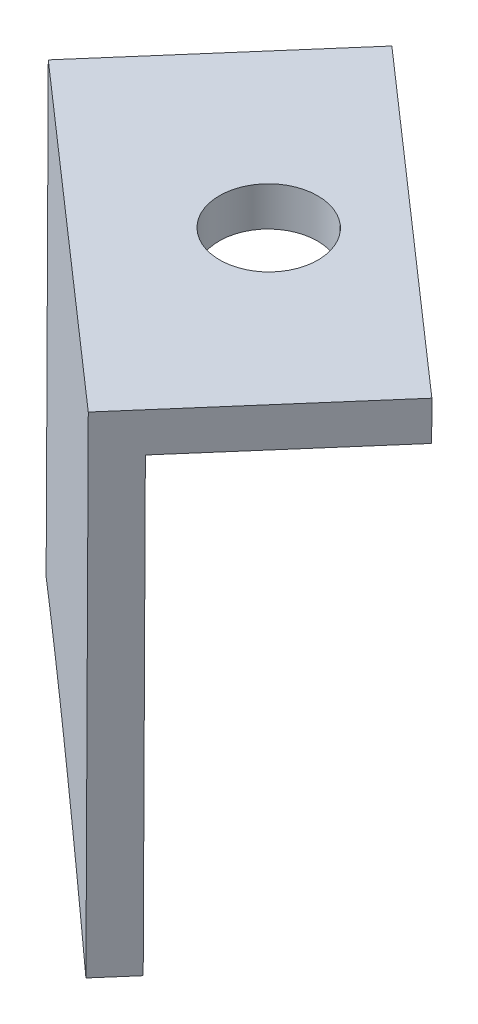
from build123d import *

# Parameters (mm, degrees)
DODANIE_WYCI_GNI_CIE1_DEPTH       = 2
WYCI_GNI_CIE_CIENKA_CIANKA1_DEPTH = 10
SZKIC3_R                          = 2.5
WYTNIJ_WYCI_GNI_CIE1_DEPTH        = 10


with BuildPart() as part:
    # Szkic1 → Dodanie-wyciągnięcie1 (new body)
    with BuildSketch(Plane(origin=(184.050171811, 0, -211.725502995), x_dir=(-0.75470958, 0, -0.656059029), z_dir=(0.656059029, 0, -0.75470958))):
        with BuildLine():
            Line((-722.617736481, -314.120725024), (-723.785887875, -289.14803149))
            Line((-723.785887875, -289.14803149), (-703.807733048, -288.213510375))
            Line((-703.807733048, -288.213510375), (-702.74076796, -311.023047123))
            add(Edge.make_bspline(
                [(-722.617736481, -314.120725024), (-715.581558407, -312.012536185), (-708.710440218, -310.976356299), (-702.74076796, -311.023047123)],
                knots=[0.744519777, 0.744519777, 0.744519777, 0.744519777, 0.831521887, 0.831521887, 0.831521887, 0.831521887], degree=3, weights=[0.500240263, 0.497697377, 0.515339471, 0.553166544]))
        make_face()
    extrude(amount=DODANIE_WYCI_GNI_CIE1_DEPTH)

    # Szkic2 → Wyciągnięcie-cienka ścianka1 (add)
    with BuildSketch(Plane(origin=(185.362289869, 0, -213.234922155), x_dir=(-0.75470958, 0, -0.656059029), z_dir=(0.656059029, 0, -0.75470958))):
        Polygon((-723.785887875, -289.14803149), (-703.807733048, -288.213510375), (-703.714280936, -290.211325858), (-723.692435763, -291.145846973), align=None)
    extrude(amount=WYCI_GNI_CIE_CIENKA_CIANKA1_DEPTH)

    # Szkic3 → Wytnij-wyciągnięcie1 (cut)
    with BuildSketch(Plane(origin=(-9.063445171, -256.731823112, -7.878732686), x_dir=(-0.999377978, 0.035240125, 0.001338532), z_dir=(-0.035264602, -0.998907741, -0.030655051))):
        with Locations((-736.736241375, -260.210465694)):
            Circle(SZKIC3_R)
    extrude(amount=-WYTNIJ_WYCI_GNI_CIE1_DEPTH, mode=Mode.SUBTRACT)


solid = part.part
